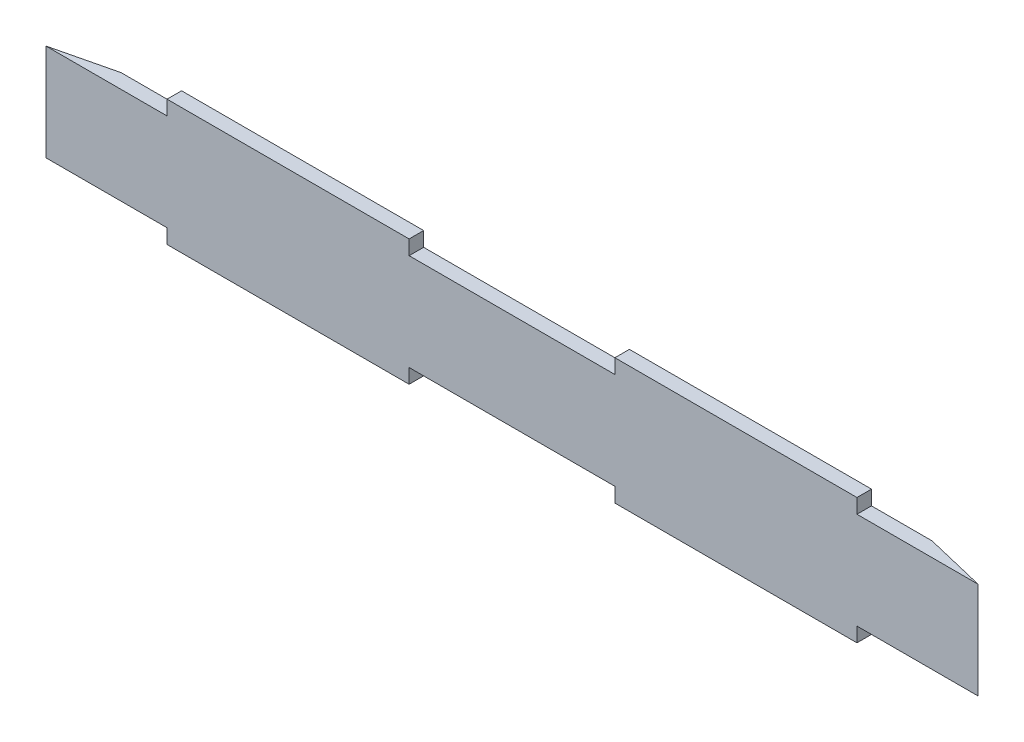
from build123d import *

# Parameters (mm, degrees)
ESQUISSE1_W             = 385
ESQUISSE1_H             = 40
BOSS_EXTRU_1_DEPTH      = 6
ESQUISSE3_W             = 100
ESQUISSE3_H             = 6
BOSS_EXTRU_2_DEPTH      = 6
ENL_V_MAT_EXTRU_1_DEPTH = 47


with BuildPart() as part:
    # Esquisse1 → Boss.-Extru.1 (new body)
    with BuildSketch(Plane.XY):
        Rectangle(ESQUISSE1_W, ESQUISSE1_H)
    extrude(amount=BOSS_EXTRU_1_DEPTH)

    # Esquisse3 → Boss.-Extru.2 (add)
    with BuildSketch(Plane.XY.offset(6)):
        with Locations((-92.5, 23)):
            Rectangle(ESQUISSE3_W, ESQUISSE3_H)
        with Locations((92.5, 23)):
            Rectangle(ESQUISSE3_W, ESQUISSE3_H)
        with Locations((92.5, -23)):
            Rectangle(ESQUISSE3_W, ESQUISSE3_H)
        with Locations((-92.5, -23)):
            Rectangle(ESQUISSE3_W, ESQUISSE3_H)
    extrude(amount=-BOSS_EXTRU_2_DEPTH)

    # Esquisse4 → Enlèv. mat.-Extru.1 (cut, through all)
    with BuildSketch(Plane(origin=(0, 20, 0), x_dir=(1, 0, 0), z_dir=(0, 1, 0))):
        Polygon((-192.5, -6), (-167.5, 0), (-192.5, 0), align=None)
        Polygon((192.5, -6), (167.5, 0), (192.5, 0), align=None)
    extrude(amount=-ENL_V_MAT_EXTRU_1_DEPTH, mode=Mode.SUBTRACT)


solid = part.part
